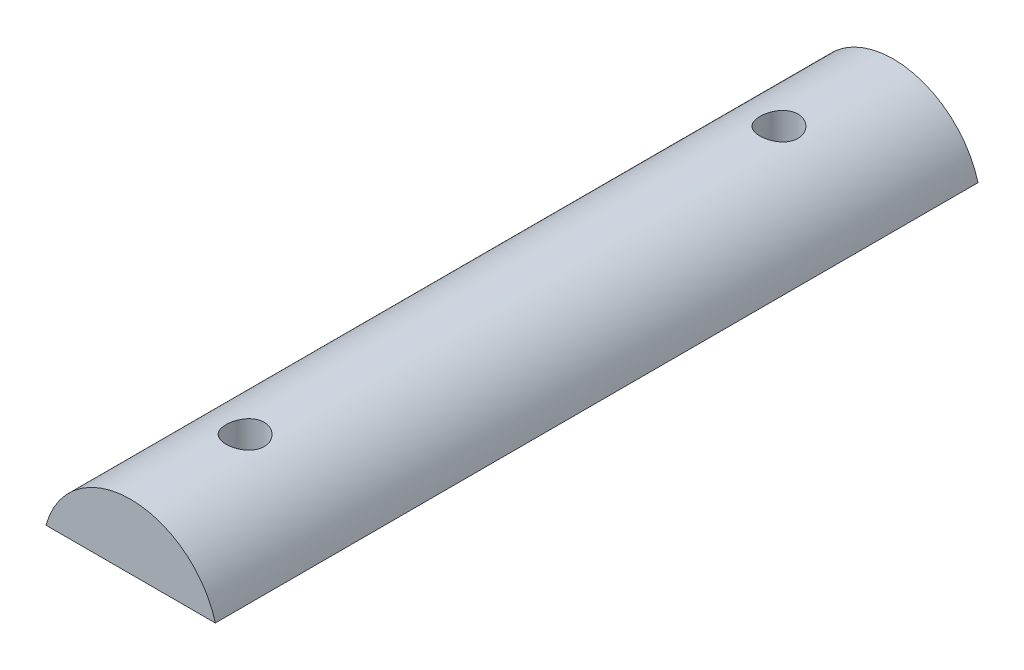
from build123d import *

# Parameters (mm, degrees)
SALIENTE_EXTRUIR1_DEPTH = 100
CORTAR_EXTRUIR1_DEPTH   = 4
CROQUIS3_R              = 2.5
CORTAR_EXTRUIR2_DEPTH   = 14


with BuildPart() as part:
    # Croquis1 → Saliente-Extruir1 (new body)
    with BuildSketch(Plane.XY):
        with BuildLine():
            Line((-47.556708367, 5.923922341), (-25.353105055, 5.923922341))
            ThreePointArc((-25.353105055, 5.923922341), (-36.454906711, 14.423922341), (-47.556708367, 5.923922341))
        make_face()
    extrude(amount=SALIENTE_EXTRUIR1_DEPTH)

    # Croquis2 → Cortar-Extruir1 (cut)
    with BuildSketch(Plane.XZ.offset(-5.923922341)):
        Polygon((-36.454906711, 80.381197846), (-32.454906711, 82.690598923), (-32.454906711, 87.309401077), (-36.454906711, 89.618802154), (-40.454906711, 87.309401077), (-40.454906711, 82.690598923), align=None)
        Polygon((-36.454906711, 10.381197846), (-32.454906711, 12.690598923), (-32.454906711, 17.309401077), (-36.454906711, 19.618802154), (-40.454906711, 17.309401077), (-40.454906711, 12.690598923), align=None)
    extrude(amount=-CORTAR_EXTRUIR1_DEPTH, mode=Mode.SUBTRACT)

    # Croquis3 → Cortar-Extruir2 (cut)
    with BuildSketch(Plane.XZ.offset(-9.923922341)):
        with Locations((-36.454906711, 15)):
            Circle(CROQUIS3_R)
        with Locations((-36.454906711, 85)):
            Circle(CROQUIS3_R)
    extrude(amount=-CORTAR_EXTRUIR2_DEPTH, mode=Mode.SUBTRACT)


solid = part.part
